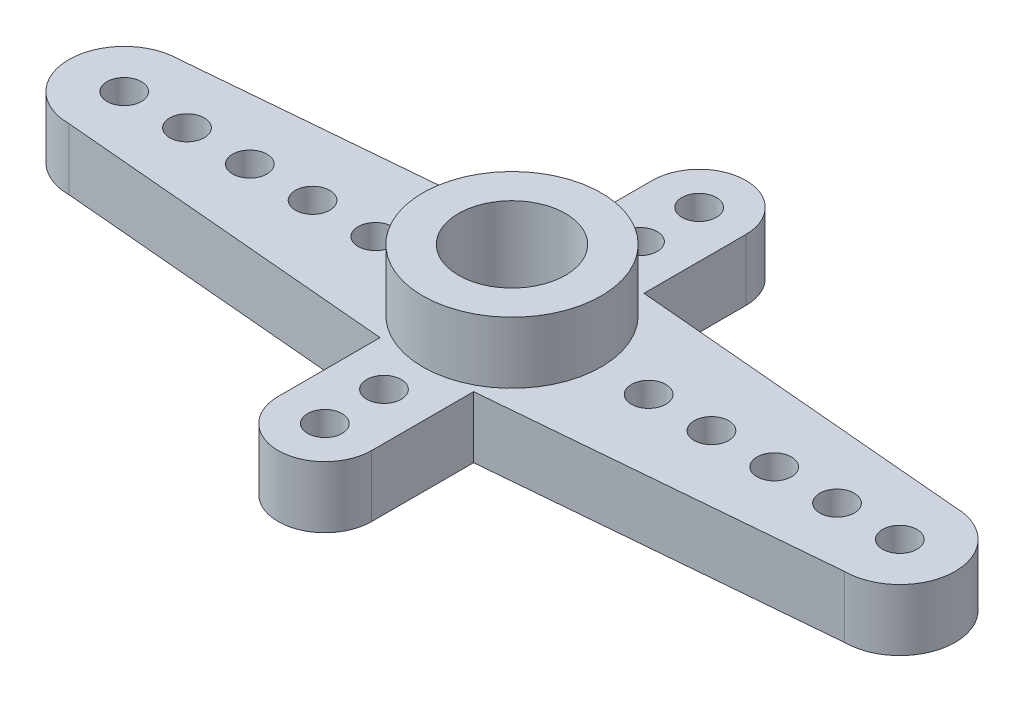
from build123d import *

# Parameters (mm, degrees)
SKETCH6_R           = 0.7
BOSS_EXTRUDE3_DEPTH = 2.5
SKETCH7_R           = 3.625
BOSS_EXTRUDE4_DEPTH = 2.5
SKETCH8_R           = 2.175
CUT_EXTRUDE3_DEPTH  = 3.4
CUT_EXTRUDE4_REACH  = 3.6
SKETCH9_R           = 1.25


with BuildPart() as part:
    # Sketch6 → Boss-Extrude3 (new body)
    with BuildSketch(Plane(origin=(0, 0, 0), x_dir=(1, 0, 0), z_dir=(0, 1, 0))):
        with BuildLine():
            Line((16.1, 7.6), (16.1, 3.459126984))
            Line((16.1, 3.459126984), (2.25, 2.25))
            ThreePointArc((2.25, 2.25), (0, 0), (2.25, -2.25))
            Line((2.25, -2.25), (16.1, -3.459126984))
            Line((16.1, -3.459126984), (16.1, -7.6))
            ThreePointArc((16.1, -7.6), (18, -9.5), (19.9, -7.6))
            Line((19.9, -7.6), (19.9, -3.459126984))
            Line((19.9, -3.459126984), (33.75, -2.25))
            ThreePointArc((33.75, -2.25), (36, 0), (33.75, 2.25))
            Line((33.75, 2.25), (19.9, 3.459126984))
            Line((19.9, 3.459126984), (19.9, 7.6))
            ThreePointArc((19.9, 7.6), (18, 9.5), (16.1, 7.6))
        make_face()
        with Locations((33.75, 0)):
            Circle(SKETCH6_R, mode=Mode.SUBTRACT)
        with Locations((31.2, 0)):
            Circle(SKETCH6_R, mode=Mode.SUBTRACT)
        with Locations((28.65, 0)):
            Circle(SKETCH6_R, mode=Mode.SUBTRACT)
        with Locations((26.1, 0)):
            Circle(SKETCH6_R, mode=Mode.SUBTRACT)
        with Locations((23.55, 0)):
            Circle(SKETCH6_R, mode=Mode.SUBTRACT)
        with Locations((18, -7.6)):
            Circle(SKETCH6_R, mode=Mode.SUBTRACT)
        with Locations((18, -5.2)):
            Circle(SKETCH6_R, mode=Mode.SUBTRACT)
        with Locations((12.45, 0)):
            Circle(SKETCH6_R, mode=Mode.SUBTRACT)
        with Locations((9.9, 0)):
            Circle(SKETCH6_R, mode=Mode.SUBTRACT)
        with Locations((7.35, 0)):
            Circle(SKETCH6_R, mode=Mode.SUBTRACT)
        with Locations((4.8, 0)):
            Circle(SKETCH6_R, mode=Mode.SUBTRACT)
        with Locations((2.25, 0)):
            Circle(SKETCH6_R, mode=Mode.SUBTRACT)
        with Locations((18, 5.2)):
            Circle(SKETCH6_R, mode=Mode.SUBTRACT)
        with Locations((18, 7.6)):
            Circle(SKETCH6_R, mode=Mode.SUBTRACT)
    extrude(amount=BOSS_EXTRUDE3_DEPTH)

    # Sketch7 → Boss-Extrude4 (add)
    with BuildSketch(Plane(origin=(0, 2.5, 0), x_dir=(1, 0, 0), z_dir=(0, 1, 0))):
        with Locations((18, 0)):
            Circle(SKETCH7_R)
    extrude(amount=BOSS_EXTRUDE4_DEPTH)

    # Sketch8 → Cut-Extrude3 (cut)
    with BuildSketch(Plane(origin=(0, 5, 0), x_dir=(1, 0, 0), z_dir=(0, 1, 0))):
        with Locations((18, 0)):
            Circle(SKETCH8_R)
    extrude(amount=-CUT_EXTRUDE3_DEPTH, mode=Mode.SUBTRACT)

    # Sketch9 → Cut-Extrude4 (cut, up to next)
    with BuildSketch(Plane(origin=(0, 1.6, 0), x_dir=(1, 0, 0), z_dir=(0, 1, 0)), mode=Mode.PRIVATE) as cut_extrude4_sk1:
        with Locations((18, 0)):
            Circle(SKETCH9_R)
    cut_extrude4_tool1 = extrude(cut_extrude4_sk1.sketch, amount=-CUT_EXTRUDE4_REACH, mode=Mode.PRIVATE) & part.part
    add(cut_extrude4_tool1.solids().sort_by_distance((18, 1.6, 0))[0], mode=Mode.SUBTRACT)


solid = part.part
